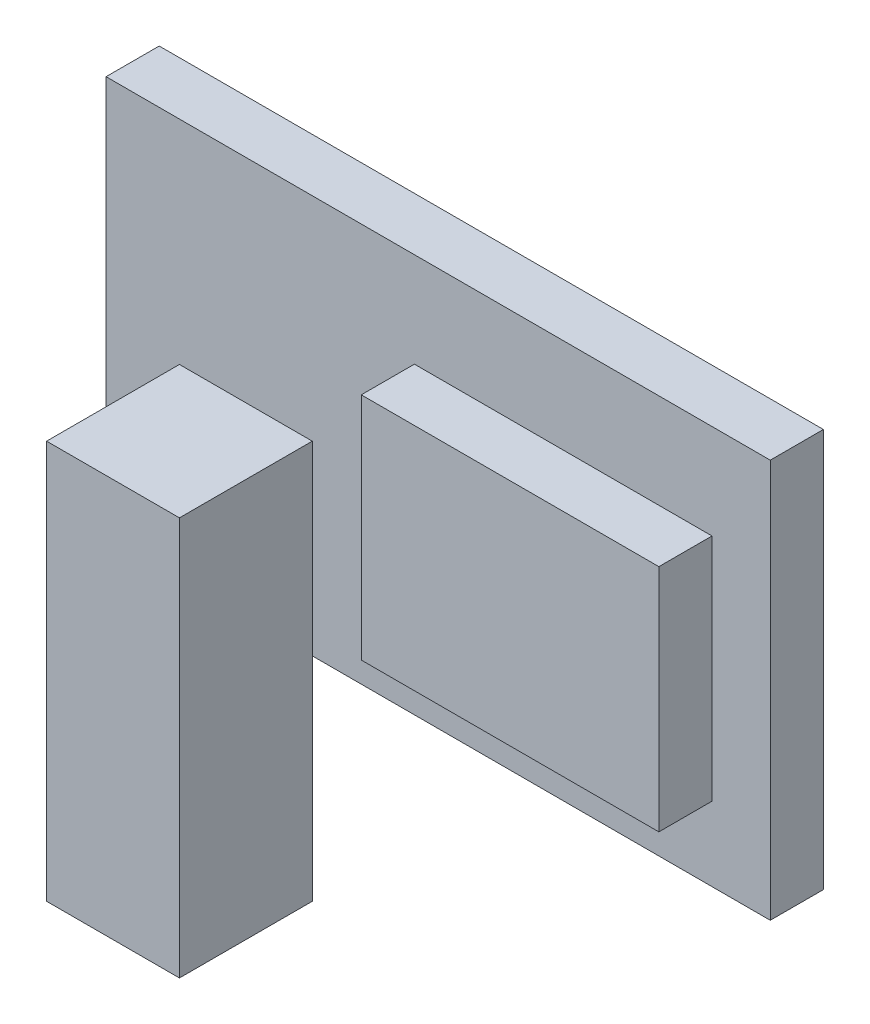
from build123d import *

# Parameters (mm, degrees)
SKETCH_2_W      = 25
SKETCH_2_H      = 15
EXTRUDE_1_DEPTH = 2
SKETCH_4_R      = 1.75
EXTRUDE_2_DEPTH = 7
SKETCH_5_W      = 5
SKETCH_5_H      = 5
EXTRUDE_3_DEPTH = 2
EXTRUDE_START   = 2
SKETCH_4_3_R    = 1.75
EXTRUDE_4_DEPTH = 2
SKETCH_7_W      = 11.201035141
SKETCH_7_H      = 8.645905099
EXTRUDE_5_DEPTH = 2
EXTRUDE_START_2 = 8
SKETCH_4_4_R    = 1.75
EXTRUDE_6_DEPTH = 8


with BuildPart() as part:
    # 草图2 → 凸台-拉伸1 (new body)
    with BuildSketch(Plane.XY):
        with Locations((-1.845610675, -3.40346801)):
            Rectangle(SKETCH_2_W, SKETCH_2_H)
    extrude(amount=EXTRUDE_1_DEPTH)

    # 草图4 → 凸台-拉伸2 (add)
    with BuildSketch(Plane.XZ.offset(10.90346801)):
        Polygon((-11.584222065, 7), (-11.584222065, 2), (-11.507000867, 2), (-6.584222065, 2), (-6.584222065, 7), align=None)
        with Locations((-9.064916765, 4.5)):
            Circle(SKETCH_4_R, mode=Mode.SUBTRACT)
    extrude(amount=-EXTRUDE_2_DEPTH)

    # 草图5 → 凸台-拉伸3 (add)
    with BuildSketch(Plane(origin=(0, -3.90346801, 0), x_dir=(1, 0, 0), z_dir=(0, 1, 0))):
        with Locations((-9.084222065, -4.5)):
            Rectangle(SKETCH_5_W, SKETCH_5_H)
    extrude(amount=-EXTRUDE_3_DEPTH)

    # 草图4<3> → 凸台-拉伸4 (add)
    with BuildSketch(Plane.XZ.offset(10.90346801).offset(EXTRUDE_START)):
        Polygon((-11.584222065, 7), (-11.584222065, 2), (-11.507000867, 2), (-6.584222065, 2), (-6.584222065, 7), align=None)
        with Locations((-9.064916765, 4.5)):
            Circle(SKETCH_4_3_R, mode=Mode.SUBTRACT)
    extrude(amount=-EXTRUDE_4_DEPTH)

    # 草图7 → 凸台-拉伸5 (add)
    with BuildSketch(Plane.XY.offset(2)):
        with Locations((2.86075116, -3.79430768)):
            Rectangle(SKETCH_7_W, SKETCH_7_H)
    extrude(amount=EXTRUDE_5_DEPTH)

    # 草图4<4> → 凸台-拉伸6 (add)
    with BuildSketch(Plane.XZ.offset(10.90346801).offset(EXTRUDE_START_2)):
        Polygon((-11.584222065, 7), (-11.584222065, 2), (-11.507000867, 2), (-6.584222065, 2), (-6.584222065, 7), align=None)
        with Locations((-9.064916765, 4.5)):
            Circle(SKETCH_4_4_R, mode=Mode.SUBTRACT)
    extrude(amount=-EXTRUDE_6_DEPTH)


solid = part.part
